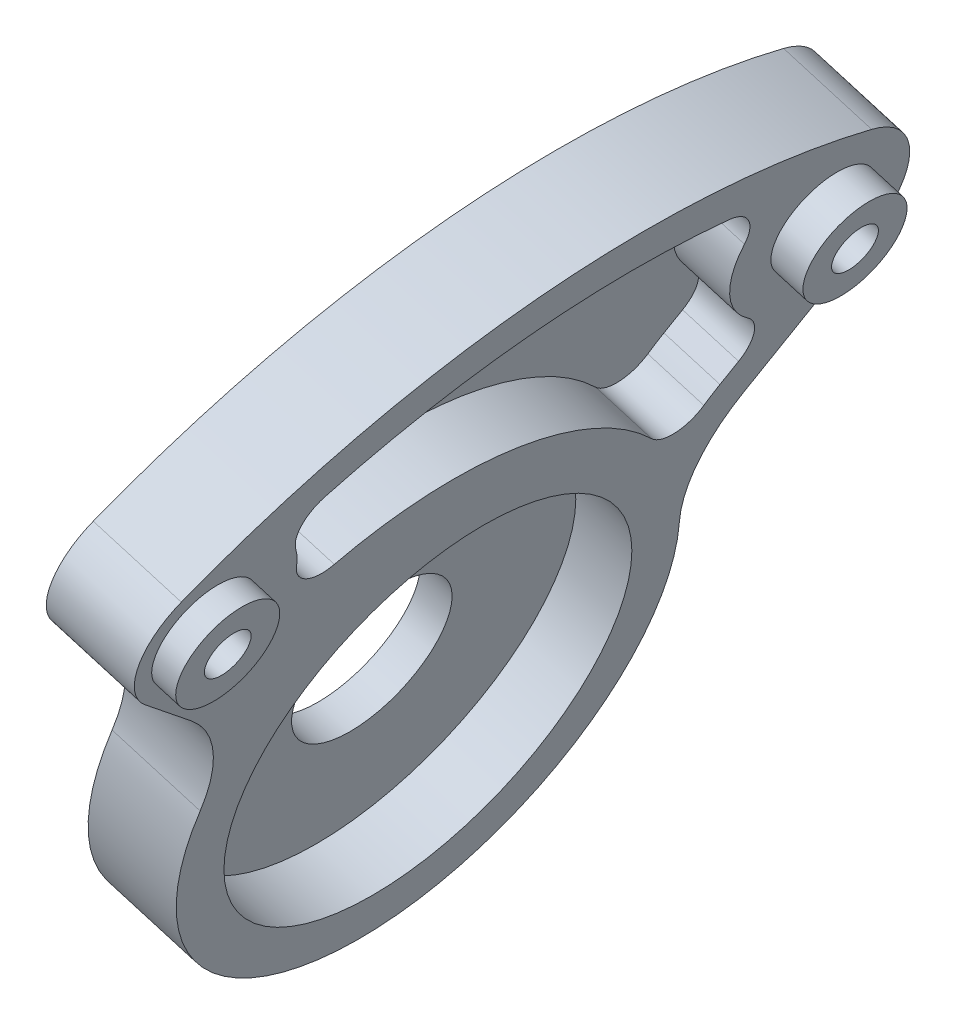
from build123d import *

# Parameters (mm, degrees)
BOSS_EXTRUDE1_DEPTH = 5.5
SKETCH2_R           = 3
BOSS_EXTRUDE2_DEPTH = 1.5
SKETCH3_R           = 1.35
CUT_EXTRUDE1_DEPTH  = 17.840471554
SKETCH4_R           = 3
BOSS_EXTRUDE3_DEPTH = 2
SKETCH5_R           = 1.35
CUT_EXTRUDE2_DEPTH  = 18.585311609
SKETCH6_R           = 11.75
CUT_EXTRUDE3_DEPTH  = 3.5
SKETCH7_R           = 4.625
CUT_EXTRUDE4_DEPTH  = 18.585311609
CUT_EXTRUDE5_DEPTH  = 3.5


with BuildPart() as part:
    # Sketch1 → Boss-Extrude1 (new body)
    with BuildSketch(Plane(origin=(65.356779706, -19.323104474, 0), x_dir=(-0.28352355, -0.958965274, 0), z_dir=(-0.958965274, 0.28352355, 0))):
        with BuildLine():
            Line((-22.409230804, 105.535335292), (-25.708238472, 109.248684924))
            ThreePointArc((-25.708238472, 109.248684924), (-28.941829317, 110.584612338), (-31.989317839, 108.866000829))
            ThreePointArc((-31.989317839, 108.866000829), (-39.5119826, 89.676955929), (-37.690186632, 69.146710224))
            ThreePointArc((-37.690186632, 69.146710224), (-34.240446028, 65.888665427), (-29.622491121, 66.979563497))
            Line((-29.622491121, 66.979563497), (-23.166630632, 72.715067926))
            ThreePointArc((-23.166630632, 72.715067926), (-19.824639339, 74.487704396), (-16.041831895, 74.526610749))
            ThreePointArc((-16.041831895, 74.526610749), (1.733883997, 88.181945854), (-15.123670288, 102.955811829))
            ThreePointArc((-15.123670288, 102.955811829), (-19.098619321, 103.307401938), (-22.409230804, 105.535335292))
        make_face()
    extrude(amount=-BOSS_EXTRUDE1_DEPTH)

    # Sketch2 → Boss-Extrude2 (add)
    with BuildSketch(Plane(origin=(70.631088713, -20.882483997, 0), x_dir=(0, 0, -1), z_dir=(0.958965274, -0.28352355, 0))):
        with Locations((-106.592015807, 28.69857444)):
            Circle(SKETCH2_R)
    extrude(amount=BOSS_EXTRUDE2_DEPTH)

    # Sketch3 → Cut-Extrude1 (cut, through all)
    with BuildSketch(Plane(origin=(65.356779706, -19.323104474, 0), x_dir=(0, 0, 1), z_dir=(-0.958965274, 0.28352355, 0))):
        with Locations((106.592015807, 28.69857444)):
            Circle(SKETCH3_R)
    extrude(amount=-CUT_EXTRUDE1_DEPTH, mode=Mode.SUBTRACT)

    # Sketch4 → Boss-Extrude3 (add)
    with BuildSketch(Plane(origin=(70.631088713, -20.882483997, 0), x_dir=(0, 0, -1), z_dir=(0.958965274, -0.28352355, 0))):
        with Locations((-70.717483457, 32.943327517)):
            Circle(SKETCH4_R)
    extrude(amount=BOSS_EXTRUDE3_DEPTH)

    # Sketch5 → Cut-Extrude2 (cut, through all)
    with BuildSketch(Plane(origin=(65.356779706, -19.323104474, 0), x_dir=(0, 0, 1), z_dir=(-0.958965274, 0.28352355, 0))):
        with Locations((70.717483457, 32.943327517)):
            Circle(SKETCH5_R)
    extrude(amount=-CUT_EXTRUDE2_DEPTH, mode=Mode.SUBTRACT)

    # Sketch6 → Cut-Extrude3 (cut)
    with BuildSketch(Plane(origin=(70.631088713, -20.882483997, 0), x_dir=(0, 0, -1), z_dir=(0.958965274, -0.28352355, 0))):
        with Locations((-88.65, 12.758559735)):
            Circle(SKETCH6_R)
    extrude(amount=-CUT_EXTRUDE3_DEPTH, mode=Mode.SUBTRACT)

    # Sketch7 → Cut-Extrude4 (cut, through all)
    with BuildSketch(Plane(origin=(65.356779706, -19.323104474, 0), x_dir=(0, 0, 1), z_dir=(-0.958965274, 0.28352355, 0))):
        with Locations((88.65, 12.758559735)):
            Circle(SKETCH7_R)
    extrude(amount=-CUT_EXTRUDE4_DEPTH, mode=Mode.SUBTRACT)

    # Sketch8 → Cut-Extrude5 (cut)
    with BuildSketch(Plane(origin=(70.631088713, -20.882483997, 0), x_dir=(0, 0, -1), z_dir=(0.958965274, -0.28352355, 0))):
        with BuildLine():
            Line((-74.584027906, 24.82704883), (-73.736581379, 25.780931199))
            ThreePointArc((-73.736581379, 25.780931199), (-73.240380162, 27.294869383), (-74.007814455, 28.691031651))
            ThreePointArc((-74.007814455, 28.691031651), (-75.840549655, 31.311613406), (-75.860990165, 34.509417221))
            ThreePointArc((-75.860990165, 34.509417221), (-76.089806816, 36.170205007), (-77.502198812, 37.073378292))
            ThreePointArc((-77.502198812, 37.073378292), (-89.36916003, 37.030513551), (-100.761658133, 33.708226249))
            ThreePointArc((-100.761658133, 33.708226249), (-101.817813371, 32.571238358), (-101.742925567, 31.021207013))
            ThreePointArc((-101.742925567, 31.021207013), (-101.4721051, 30.340162869), (-101.296421193, 29.628615248))
            ThreePointArc((-101.296421193, 29.628615248), (-100.31044829, 28.233312085), (-98.606486741, 28.10869859))
            ThreePointArc((-98.606486741, 28.10869859), (-87.819157421, 28.939652392), (-78.355573806, 23.695842402))
            ThreePointArc((-78.355573806, 23.695842402), (-76.768954569, 23.099003898), (-75.294048195, 23.934604274))
            ThreePointArc((-75.294048195, 23.934604274), (-74.951163338, 24.390473315), (-74.584027906, 24.82704883))
        make_face()
    extrude(amount=-CUT_EXTRUDE5_DEPTH, mode=Mode.SUBTRACT)


solid = part.part
